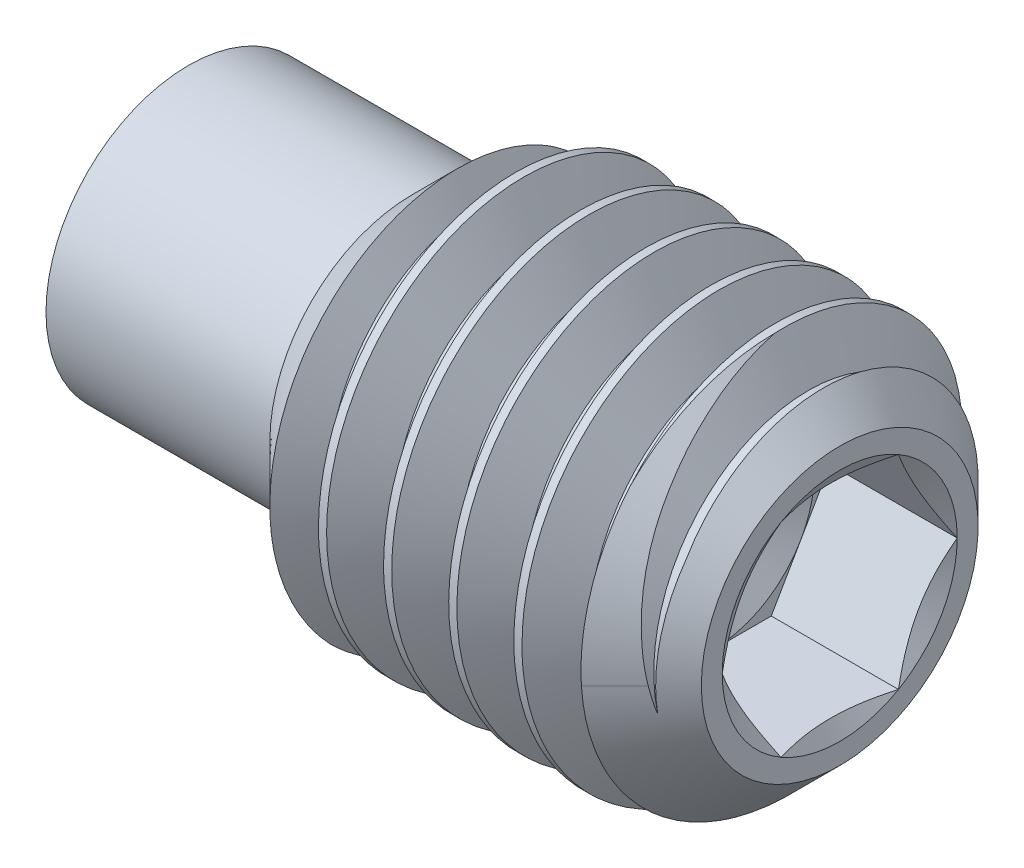
from build123d import *

# Parameters (mm, degrees)
CUT_EXTRUDE1_DEPTH     = 1.5625
CUT_SWEEP1_PITCH       = 0.8
CUT_SWEEP1_HEIGHT      = 6.05
CUT_SWEEP1_RADIUS      = 2.5
CUT_SWEEP1_START_ANGLE = -90


with BuildPart() as part:
    # Sketch2 → Revolve1 (revolve)
    with BuildSketch(Plane.XY, mode=Mode.PRIVATE) as revolve1_sk:
        Polygon((-4, 0), (-4, 1.75), (-1.25, 1.75), (-0.5, 2.5), (3.2, 2.5), (4, 1.7), (4, 0), align=None)
    revolve(revolve1_sk.sketch.rotate(Axis((-4, 0, 0), (1, 0, 0)), 90), axis=Axis((-4, 0, 0), (1, 0, 0)))

    # Sketch3 → Cut-Extrude1 (cut)
    with BuildSketch(Plane(origin=(4, 0, 0), x_dir=(0, 0, -1), z_dir=(1, 0, 0))):
        Polygon((0.721687836, 1.25), (-0.721687836, 1.25), (-1.443375673, 0), (-0.721687836, -1.25), (0.721687836, -1.25), (1.443375673, 0), align=None)
    extrude(amount=-CUT_EXTRUDE1_DEPTH, mode=Mode.SUBTRACT)

    # Cut-Extrude2 cone 1 section (through the dimple's axis) → Cut-Extrude2 (revolve, cut)
    with BuildSketch(Plane(origin=(4, 0, 0), x_dir=(0, 0, -1), z_dir=(0, 1, 0))):
        Polygon((0, 0), (1.443375673, 0), (0, 0.833333333), align=None)
    revolve(axis=Axis((4, 0, 0), (-1, 0, 0)), mode=Mode.SUBTRACT)

    # Cut-Extrude3 cone 1 section (through the dimple's axis) → Cut-Extrude3 (revolve, cut)
    with BuildSketch(Plane(origin=(2.4375, 0, 0), x_dir=(0, 0, -1), z_dir=(0, 1, 0))):
        Polygon((0, 0), (1.25, 0), (0, 0.721687836), align=None)
    revolve(axis=Axis((2.4375, 0, 0), (-1, 0, 0)), mode=Mode.SUBTRACT)

    # Cut-Sweep1: sweep along a helix
    with BuildLine() as cut_sweep1_path:
        add(Helix(CUT_SWEEP1_PITCH, CUT_SWEEP1_HEIGHT, CUT_SWEEP1_RADIUS, center=(4, 0, 0), direction=(-1, 0, 0), mode=Mode.PRIVATE).rotate(Axis((4, 0, 0), (-1, 0, 0)), CUT_SWEEP1_START_ANGLE))
    # Sketch6 → Cut-Sweep1 (sweep, cut)
    with BuildSketch(Plane.XY):
        Polygon((3.975, 2.54330127), (4.725, 2.54330127), (4.4, 1.980384758), (4.3, 1.980384758), align=None)
    sweep(path=cut_sweep1_path.line, is_frenet=True, mode=Mode.SUBTRACT)


solid = part.part
